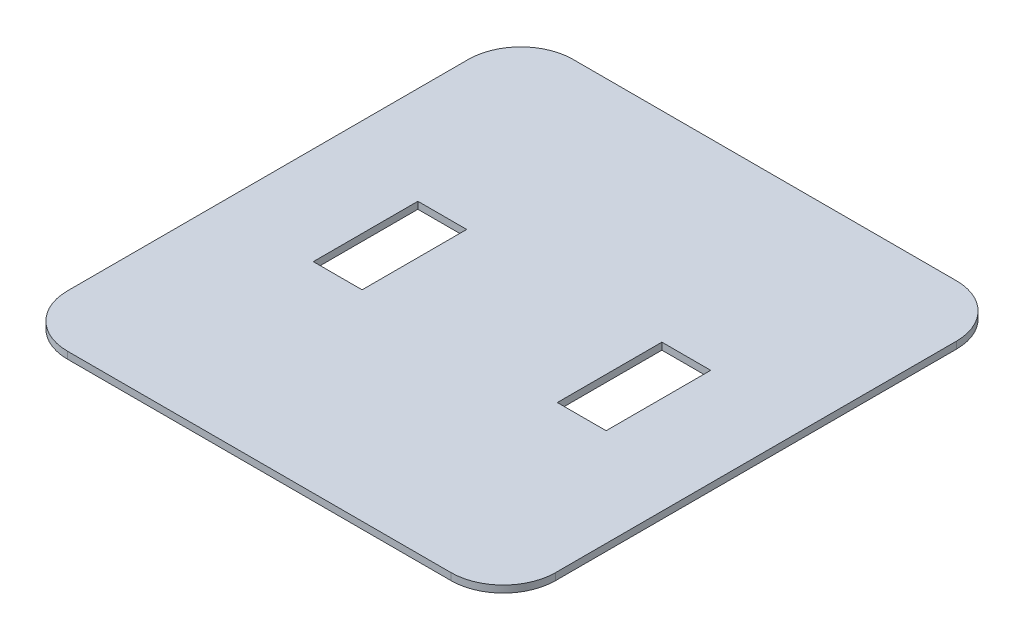
from build123d import *

# Parameters (mm, degrees)
ESQUISSE1_W      = 28
ESQUISSE1_H      = 60
EXTRUSION1_DEPTH = 4


with BuildPart() as part:
    # Esquisse1 → Extrusion1 (new body)
    with BuildSketch(Plane(origin=(0, 0, 0), x_dir=(1, 0, 0), z_dir=(0, 1, 0))):
        with BuildLine():
            Line((110, 0), (-110, 0))
            ThreePointArc((-110, 0), (-131.213203436, -8.786796564), (-140, -30))
            Line((-140, -30), (-140, -260))
            ThreePointArc((-140, -260), (-131.213203436, -281.213203436), (-110, -290))
            Line((-110, -290), (110, -290))
            ThreePointArc((110, -290), (131.213203436, -281.213203436), (140, -260))
            Line((140, -260), (140, -30))
            ThreePointArc((140, -30), (131.213203436, -8.786796564), (110, 0))
        make_face()
        with Locations((70, -145)):
            Rectangle(ESQUISSE1_W, ESQUISSE1_H, mode=Mode.SUBTRACT)
        with Locations((-70, -145)):
            Rectangle(ESQUISSE1_W, ESQUISSE1_H, mode=Mode.SUBTRACT)
    extrude(amount=EXTRUSION1_DEPTH)


solid = part.part
